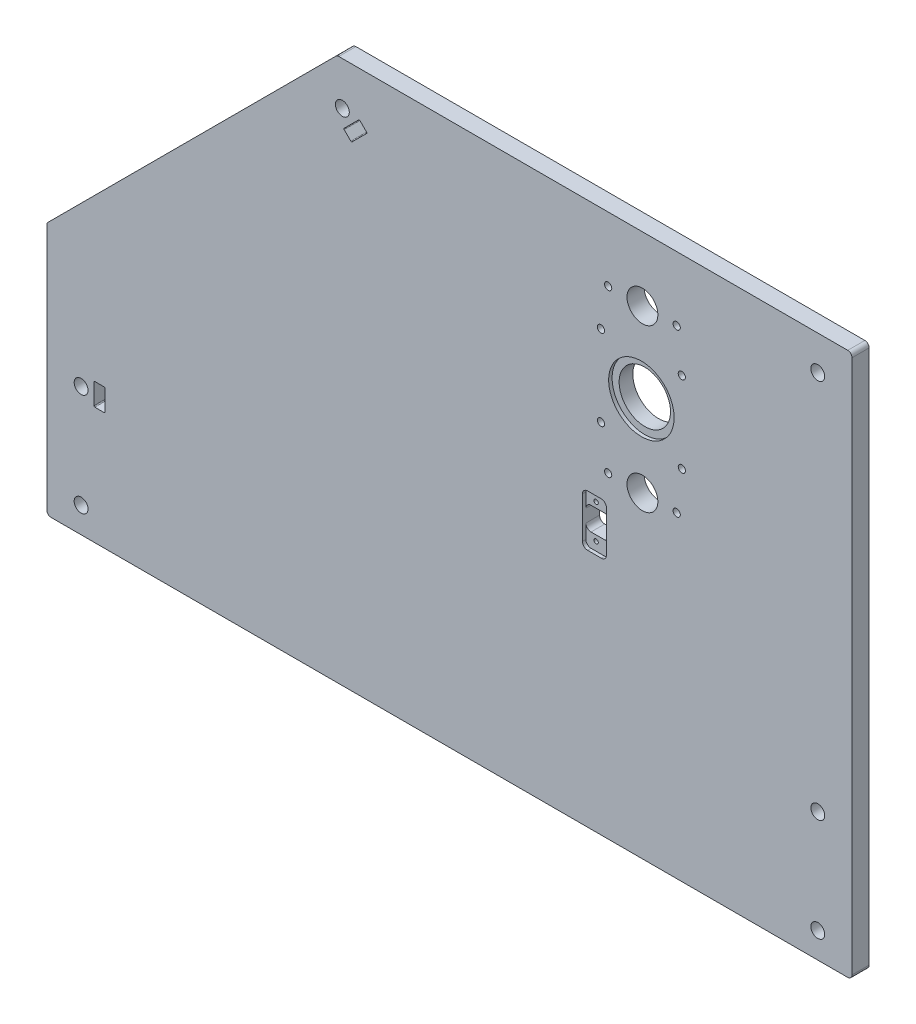
from build123d import *

# Parameters (mm, degrees)
SKETCH2_W             = 470
SKETCH2_H             = 317
BOSS_EXTRUDE1_DEPTH   = 5
SKETCH3_R             = 4.05
CUT_EXTRUDE1_DEPTH    = 10
SKETCH4_R             = 9
CUT_EXTRUDE2_DEPTH    = 11
M5X0_8_TAPPED_HOLE1_D = 4.2
SKETCH7_R             = 19.1
CUT_EXTRUDE5_DEPTH    = 2
M5X0_8_TAPPED_HOLE2_D = 4.2
SKETCH19_R            = 15
CUT_EXTRUDE10_DEPTH   = 9
SKETCH20_W            = 14
SKETCH20_H            = 30
CUT_EXTRUDE11_DEPTH   = 2
M3X0_5_TAPPED_HOLE2_D = 2.5
SKETCH23_W            = 14
SKETCH23_H            = 13.5
CUT_EXTRUDE13_DEPTH   = 9
CUT_EXTRUDE14_DEPTH   = 11
FILLET1_R             = 3
FILLET2_R             = 2.5
SKETCH27_R            = 4.05
CUT_EXTRUDE15_DEPTH   = 11
CUT_EXTRUDE16_DEPTH   = 11
CUT_EXTRUDE17_DEPTH   = 11


with BuildPart() as part:
    # Sketch2 → Boss-Extrude1 (new body, symmetric)
    with BuildSketch(Plane.XY):
        Rectangle(SKETCH2_W, SKETCH2_H)
    extrude(amount=BOSS_EXTRUDE1_DEPTH, both=True)

    # Sketch3 → Cut-Extrude1 (cut)
    with BuildSketch(Plane.XY.offset(5)):
        with Locations((-215, -83.5)):
            Circle(SKETCH3_R)
        with Locations((-215, -143.5)):
            Circle(SKETCH3_R)
        with Locations((215, -143.5)):
            Circle(SKETCH3_R)
        with Locations((-62.5, 133.34)):
            Circle(SKETCH3_R)
        with Locations((215, 138.5)):
            Circle(SKETCH3_R)
    extrude(amount=-CUT_EXTRUDE1_DEPTH, mode=Mode.SUBTRACT)

    # Sketch4 → Cut-Extrude2 (cut, through all)
    with BuildSketch(Plane.XY.offset(5)):
        with Locations((112.65, 121)):
            Circle(SKETCH4_R)
        with Locations((112.65, 26.5)):
            Circle(SKETCH4_R)
    extrude(amount=-CUT_EXTRUDE2_DEPTH, mode=Mode.SUBTRACT)

    # M5x0.8 Tapped Hole1 (through all)
    with Locations(Plane.XY.offset(5)):
        with Locations((132.65, 121), (92.65, 121), (92.65, 26.5), (132.65, 26.5)):
            Hole(M5X0_8_TAPPED_HOLE1_D / 2)

    # Sketch7 → Cut-Extrude5 (cut)
    with BuildSketch(Plane.XY.offset(5)):
        with Locations((112.05, 73.75)):
            Circle(SKETCH7_R)
    extrude(amount=-CUT_EXTRUDE5_DEPTH, mode=Mode.SUBTRACT)

    # M5x0.8 Tapped Hole2 (through all)
    with Locations(Plane.XY.offset(5)):
        with Locations((88.45, 97.35), (135.65, 97.35), (135.65, 50.15), (88.45, 50.15)):
            Hole(M5X0_8_TAPPED_HOLE2_D / 2)

    # Sketch19 → Cut-Extrude10 (cut, through all)
    with BuildSketch(Plane.XY.offset(3)):
        with Locations((112.05, 73.75)):
            Circle(SKETCH19_R)
    extrude(amount=-CUT_EXTRUDE10_DEPTH, mode=Mode.SUBTRACT)

    # Sketch20 → Cut-Extrude11 (cut)
    with BuildSketch(Plane.XY.offset(5)):
        with Locations((84.65, -3.5)):
            Rectangle(SKETCH20_W, SKETCH20_H)
    extrude(amount=-CUT_EXTRUDE11_DEPTH, mode=Mode.SUBTRACT)

    # M3x0.5 Tapped Hole2 (through all)
    with Locations(Plane.XY.offset(3)):
        with Locations((83.65, 6.5), (83.65, -13.5)):
            Hole(M3X0_5_TAPPED_HOLE2_D / 2)

    # Sketch23 → Cut-Extrude13 (cut, through all)
    with BuildSketch(Plane.XY.offset(3)):
        with Locations((84.65, -3.5)):
            Rectangle(SKETCH23_W, SKETCH23_H)
    extrude(amount=-CUT_EXTRUDE13_DEPTH, mode=Mode.SUBTRACT)

    # Sketch26 → Cut-Extrude14 (cut, through all)
    with BuildSketch(Plane.XY.offset(5)):
        Polygon((-32.351626406, 191.772644842), (-286.046542749, -61.922271502), (-286.046542749, 282.491923936), align=None)
    extrude(amount=-CUT_EXTRUDE14_DEPTH, mode=Mode.SUBTRACT)

    # Fillet1
    fillet1_edges = [part.edges().sort_by_distance(p)[0] for p in [
        (77.65, 11.5, 4),
        (91.65, 3.25, -1),
        (91.65, -10.25, -1),
        (77.65, -10.25, -1),
        (77.65, 3.25, -1),
        (91.65, 11.5, 4),
        (91.65, -18.5, 4),
        (77.65, -18.5, 4),
    ]]
    fillet(fillet1_edges, radius=FILLET1_R)

    # Fillet2
    fillet2_edges = [part.edges().sort_by_distance(p)[0] for p in [
        (-65.624271247, 158.5, 0),
        (-235, -10.875728753, 0),
        (235, -158.5, 0),
        (-235, -158.5, 0),
        (235, 158.5, 0),
    ]]
    fillet(fillet2_edges, radius=FILLET2_R)

    # Sketch27 → Cut-Extrude15 (cut, through all)
    with BuildSketch(Plane.XY.offset(5)):
        with Locations((215, -83.5)):
            Circle(SKETCH27_R)
    extrude(amount=-CUT_EXTRUDE15_DEPTH, mode=Mode.SUBTRACT)

    # Sketch28 → Cut-Extrude16 (cut, through all)
    with BuildSketch(Plane.XY.offset(5)):
        with BuildLine():
            Line((-61.439339828, 123.086951673), (-57.550252532, 119.197864376))
            ThreePointArc((-57.550252532, 119.197864376), (-57.196699141, 119.051417767), (-56.843145751, 119.197864376))
            Line((-56.843145751, 119.197864376), (-48.357864376, 127.683145751))
            ThreePointArc((-48.357864376, 127.683145751), (-48.211417767, 128.036699141), (-48.357864376, 128.390252532))
            Line((-48.357864376, 128.390252532), (-52.246951673, 132.279339828))
            ThreePointArc((-52.246951673, 132.279339828), (-52.600505063, 132.425786438), (-52.954058454, 132.279339828))
            Line((-52.954058454, 132.279339828), (-61.439339828, 123.794058454))
            ThreePointArc((-61.439339828, 123.794058454), (-61.585786438, 123.440505063), (-61.439339828, 123.086951673))
        make_face()
    extrude(amount=-CUT_EXTRUDE16_DEPTH, mode=Mode.SUBTRACT)

    # Sketch29 → Cut-Extrude17 (cut, through all)
    with BuildSketch(Plane.XY.offset(5)):
        with BuildLine():
            Line((-207, -90), (-201.5, -90))
            ThreePointArc((-201.5, -90), (-201.146446609, -89.853553391), (-201, -89.5))
            Line((-201, -89.5), (-201, -77.5))
            ThreePointArc((-201, -77.5), (-201.146446609, -77.146446609), (-201.5, -77))
            Line((-201.5, -77), (-207, -77))
            ThreePointArc((-207, -77), (-207.353553391, -77.146446609), (-207.5, -77.5))
            Line((-207.5, -77.5), (-207.5, -89.5))
            ThreePointArc((-207.5, -89.5), (-207.353553391, -89.853553391), (-207, -90))
        make_face()
    extrude(amount=-CUT_EXTRUDE17_DEPTH, mode=Mode.SUBTRACT)


solid = part.part
